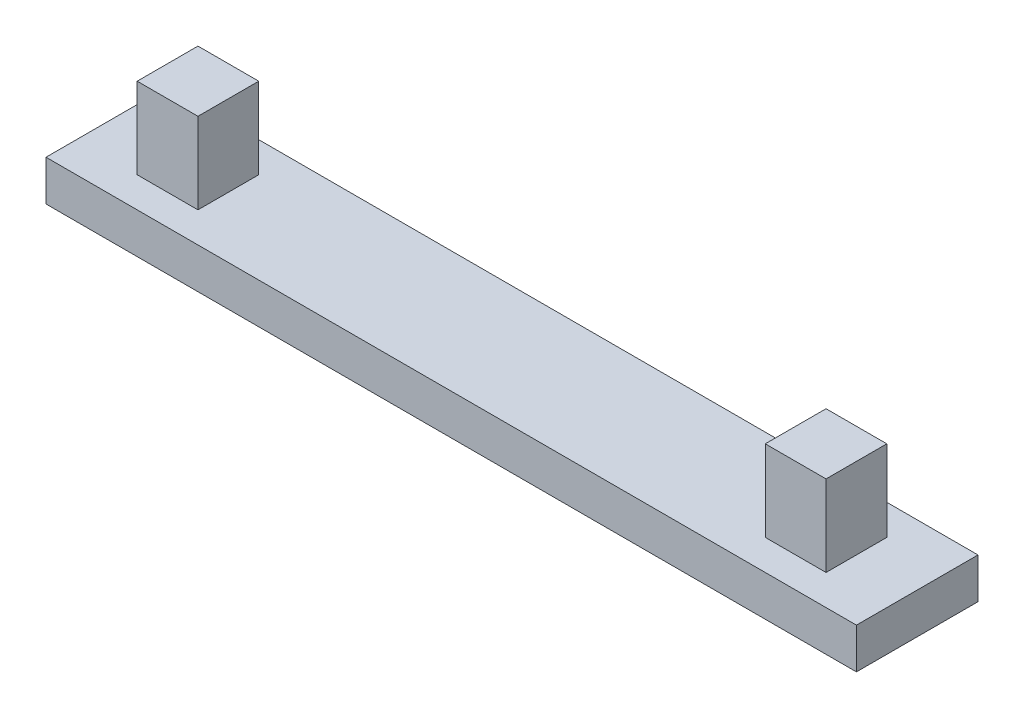
from build123d import *

# Parameters (mm, degrees)
SKETCH1_W           = 20
SKETCH1_H           = 3
SKETCH1_W_2         = 1.5
SKETCH1_H_2         = 1.5
BOSS_EXTRUDE1_DEPTH = 1
SKETCH1_3_W         = 1.5
SKETCH1_3_H         = 1.5
BOSS_EXTRUDE2_DEPTH = 3


with BuildPart() as part:
    # Sketch1 → Boss-Extrude1 (new body)
    with BuildSketch(Plane(origin=(0, 0, 0), x_dir=(1, 0, 0), z_dir=(0, 1, 0))):
        with Locations((10, 1.5)):
            Rectangle(SKETCH1_W, SKETCH1_H)
        with Locations((2.25, 1.5)):
            Rectangle(SKETCH1_W_2, SKETCH1_H_2, mode=Mode.SUBTRACT)
        with Locations((17.75, 1.5)):
            Rectangle(SKETCH1_W_2, SKETCH1_H_2, mode=Mode.SUBTRACT)
    extrude(amount=BOSS_EXTRUDE1_DEPTH)

    # Sketch1_3 → Boss-Extrude2 (add)
    with BuildSketch(Plane(origin=(0, 0, 0), x_dir=(1, 0, 0), z_dir=(0, 1, 0))):
        with Locations((2.25, 1.5)):
            Rectangle(SKETCH1_3_W, SKETCH1_3_H)
        with Locations((17.75, 1.5)):
            Rectangle(SKETCH1_3_W, SKETCH1_3_H)
    extrude(amount=BOSS_EXTRUDE2_DEPTH)


solid = part.part
